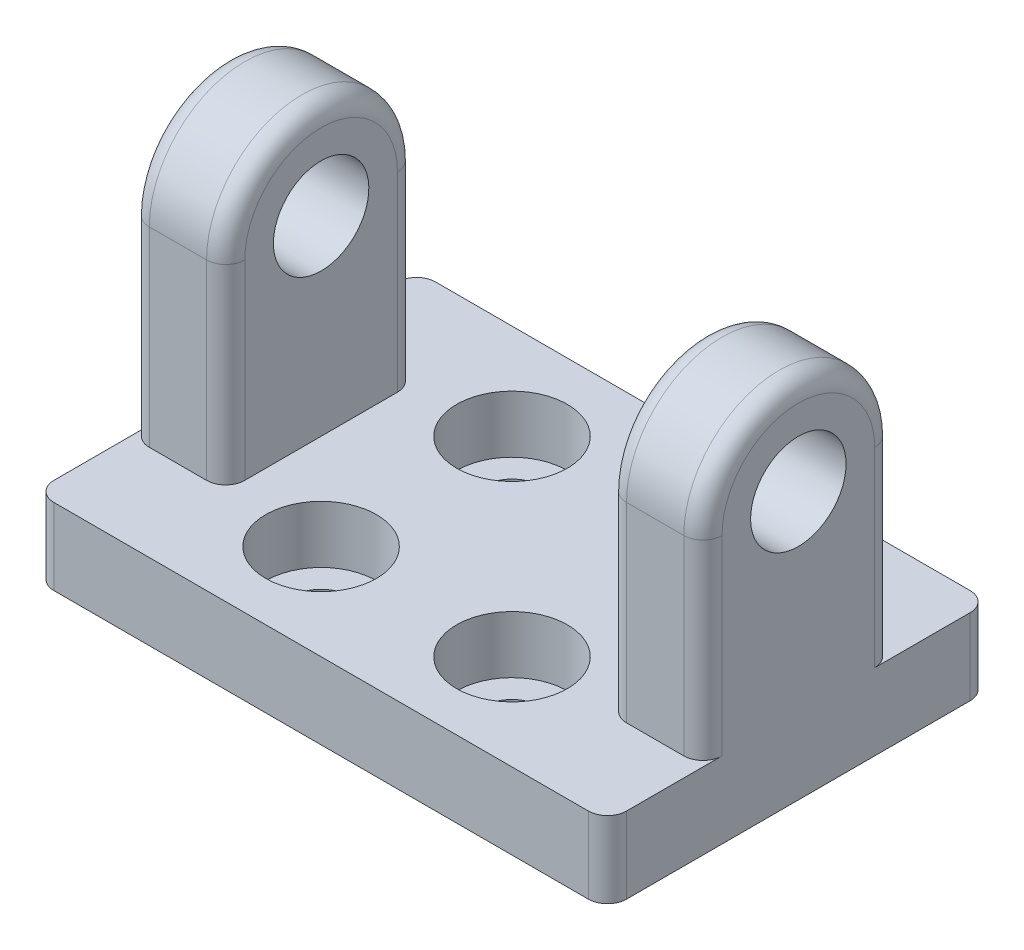
from build123d import *

# Parameters (mm, degrees)
ESQUISSE2_R             = 2.5
BOSS_EXTRU_1_DEPTH      = 15
ESQUISSE4_W             = 30
ESQUISSE4_H             = 20
BOSS_EXTRU_2_DEPTH      = 4
ENL_V_MAT_EXTRU_1_REACH = 6
ESQUISSE5_R             = 1.5
ESQUISSE6_W             = 20
ESQUISSE6_H             = 21.543710407
ENL_V_MAT_EXTRU_2_DEPTH = 16
ESQUISSE7_R             = 2.9
ENL_V_MAT_EXTRU_3_DEPTH = 3
CONG_1_R                = 1


with BuildPart() as part:
    # Esquisse2 → Boss.-Extru.1 (new body, symmetric)
    with BuildSketch(Plane(origin=(0, 0, 0), x_dir=(0, 0, -1), z_dir=(1, 0, 0))):
        with BuildLine():
            Line((5, 0), (5, -10))
            Line((5, -10), (-5, -10))
            Line((-5, -10), (-5, 0))
            ThreePointArc((-5, 0), (0, 5), (5, 0))
        make_face()
        Circle(ESQUISSE2_R, mode=Mode.SUBTRACT)
    extrude(amount=BOSS_EXTRU_1_DEPTH, both=True)

    # Esquisse4 → Boss.-Extru.2 (add)
    with BuildSketch(Plane.XZ.offset(10)):
        Rectangle(ESQUISSE4_W, ESQUISSE4_H)
    extrude(amount=BOSS_EXTRU_2_DEPTH)

    # Esquisse5 → Enlèv. mat.-Extru.1 (cut, up to next)
    with BuildSketch(Plane(origin=(0, -10, 0), x_dir=(1, 0, 0), z_dir=(0, 1, 0)), mode=Mode.PRIVATE) as enl_v_mat_extru_1_sk1:
        with Locations(Location((5, -5, 0), (0, 0, 270))):  # turned: the seam where the file's is
            Circle(ESQUISSE5_R)
    enl_v_mat_extru_1_tool1 = extrude(enl_v_mat_extru_1_sk1.sketch, amount=-ENL_V_MAT_EXTRU_1_REACH, mode=Mode.PRIVATE) & part.part
    add(enl_v_mat_extru_1_tool1.solids().sort_by_distance((5, -10, 5))[0], mode=Mode.SUBTRACT)
    # Esquisse5 → Enlèv. mat.-Extru.1 (cut, up to next)
    with BuildSketch(Plane(origin=(0, -10, 0), x_dir=(1, 0, 0), z_dir=(0, 1, 0)), mode=Mode.PRIVATE) as enl_v_mat_extru_1_sk2:
        with Locations(Location((5, 5, 0), (0, 0, 270))):  # turned: the seam where the file's is
            Circle(ESQUISSE5_R)
    enl_v_mat_extru_1_tool2 = extrude(enl_v_mat_extru_1_sk2.sketch, amount=-ENL_V_MAT_EXTRU_1_REACH, mode=Mode.PRIVATE) & part.part
    add(enl_v_mat_extru_1_tool2.solids().sort_by_distance((5, -10, -5))[0], mode=Mode.SUBTRACT)
    # Esquisse5 → Enlèv. mat.-Extru.1 (cut, up to next)
    with BuildSketch(Plane(origin=(0, -10, 0), x_dir=(1, 0, 0), z_dir=(0, 1, 0)), mode=Mode.PRIVATE) as enl_v_mat_extru_1_sk3:
        with Locations(Location((-5, 5, 0), (0, 0, 270))):  # turned: the seam where the file's is
            Circle(ESQUISSE5_R)
    enl_v_mat_extru_1_tool3 = extrude(enl_v_mat_extru_1_sk3.sketch, amount=-ENL_V_MAT_EXTRU_1_REACH, mode=Mode.PRIVATE) & part.part
    add(enl_v_mat_extru_1_tool3.solids().sort_by_distance((-5, -10, -5))[0], mode=Mode.SUBTRACT)
    # Esquisse5 → Enlèv. mat.-Extru.1 (cut, up to next)
    with BuildSketch(Plane(origin=(0, -10, 0), x_dir=(1, 0, 0), z_dir=(0, 1, 0)), mode=Mode.PRIVATE) as enl_v_mat_extru_1_sk4:
        with Locations(Location((-5, -5, 0), (0, 0, 270))):  # turned: the seam where the file's is
            Circle(ESQUISSE5_R)
    enl_v_mat_extru_1_tool4 = extrude(enl_v_mat_extru_1_sk4.sketch, amount=-ENL_V_MAT_EXTRU_1_REACH, mode=Mode.PRIVATE) & part.part
    add(enl_v_mat_extru_1_tool4.solids().sort_by_distance((-5, -10, 5))[0], mode=Mode.SUBTRACT)

    # Esquisse6 → Enlèv. mat.-Extru.2 (cut, through all)
    with BuildSketch(Plane.XY.offset(5)):
        with Locations((0, 0.771855204)):
            Rectangle(ESQUISSE6_W, ESQUISSE6_H)
    extrude(amount=-ENL_V_MAT_EXTRU_2_DEPTH, mode=Mode.SUBTRACT)

    # Esquisse7 → Enlèv. mat.-Extru.3 (cut)
    with BuildSketch(Plane(origin=(0, -10, 0), x_dir=(1, 0, 0), z_dir=(0, 1, 0))):
        with Locations(Location((-5, 5, 0), (0, 0, 270))):  # turned: the seam where the file's is
            Circle(ESQUISSE7_R)
        with Locations(Location((5, 5, 0), (0, 0, 270))):  # turned: the seam where the file's is
            Circle(ESQUISSE7_R)
        with Locations(Location((5, -5, 0), (0, 0, 270))):  # turned: the seam where the file's is
            Circle(ESQUISSE7_R)
        with Locations(Location((-5, -5, 0), (0, 0, 270))):  # turned: the seam where the file's is
            Circle(ESQUISSE7_R)
    extrude(amount=-ENL_V_MAT_EXTRU_3_DEPTH, mode=Mode.SUBTRACT)

    # Congé1
    cong_1_edges = [part.edges().sort_by_distance(p)[0] for p in [
        (15, -5, -5),
        (-15, -12, 10),
        (-15, -12, -10),
        (15, -12, -10),
        (15, -12, 10),
        (15, 5, 0),
        (-15, -5, -5),
        (-15, -5, 5),
        (-15, 5, 0),
        (-10, 5, 0),
        (-10, -5, -5),
        (10, -5, -5),
        (10, 5, 0),
        (10, -5, 5),
        (-10, -5, 5),
        (15, -5, 5),
    ]]
    fillet(cong_1_edges, radius=CONG_1_R)


solid = part.part
